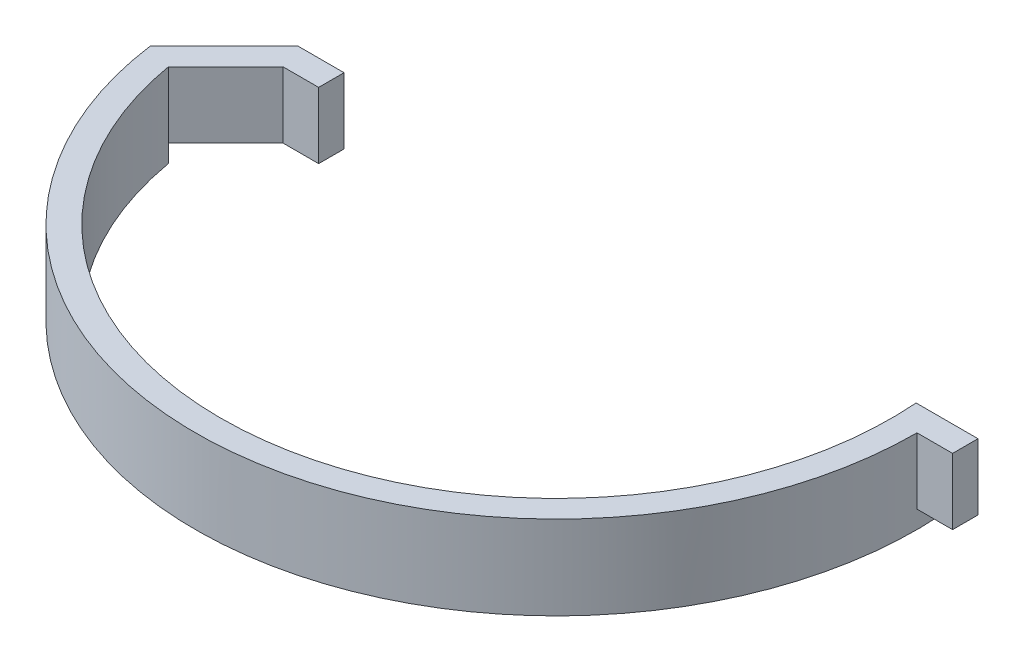
from build123d import *

# Parameters (mm, degrees)
BOSS_EXTRUDE1_DEPTH = 13
BOSS_EXTRUDE2_DEPTH = 3.5


with BuildPart() as part:
    # Sketch1 → Boss-Extrude1 (new body)
    with BuildSketch(Plane(origin=(0, 0, 0), x_dir=(1, 0, 0), z_dir=(0, 1, 0))):
        with BuildLine():
            Line((-70.343588137, -14.533254602), (-55.810333535, 0))
            Line((-55.810333535, 0), (-46.739265723, 0))
            Line((-46.739265723, 0), (-46.739265723, -5))
            Line((-46.739265723, -5), (-53.739265723, -5))
            Line((-53.739265723, -5), (-65.02750007, -16.288234347))
            ThreePointArc((-65.02750007, -16.288234347), (8.153517743, -70.494428377), (65.810333535, 0))
            Line((65.810333535, 0), (77.98664195, 0))
            Line((77.98664195, 0), (77.98664195, -5))
            Line((77.98664195, -5), (70.98664195, -5))
            ThreePointArc((70.98664195, -5), (4.777459092, -75.825696043), (-70.343588137, -14.533254602))
        make_face()
    extrude(amount=BOSS_EXTRUDE1_DEPTH)

    # Sketch2 → Boss-Extrude2 (add)
    with BuildSketch(Plane.XZ):
        with BuildLine():
            Line((-65.02750007, 16.288234347), (-68.563033976, 12.752700441))
            Line((-68.563033976, 12.752700441), (-70.343588137, 14.533254602))
            ThreePointArc((-70.343588137, 14.533254602), (7.270373797, 75.613348598), (70.810333535, 0))
            Line((70.810333535, 0), (65.810333535, 0))
            ThreePointArc((65.810333535, 0), (8.153517743, 70.494428377), (-65.02750007, 16.288234347))
        make_face()
    extrude(amount=BOSS_EXTRUDE2_DEPTH)


solid = part.part
